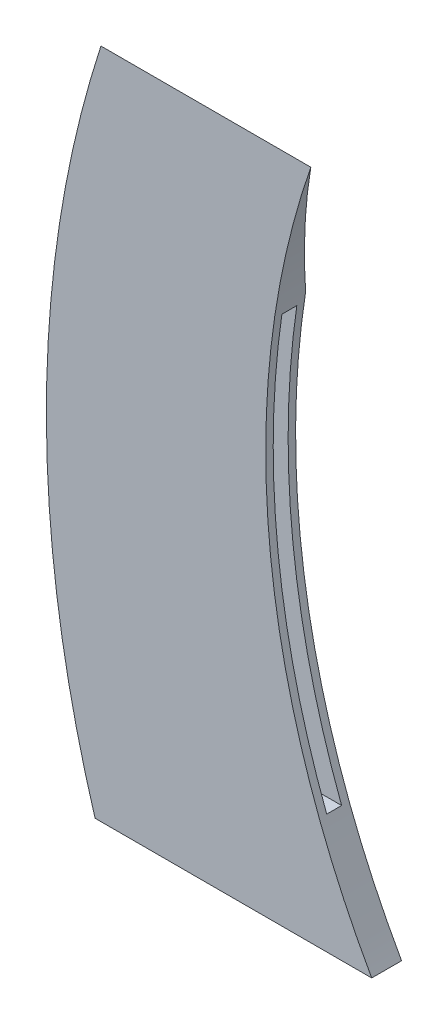
from build123d import *

# Parameters (mm, degrees)
EXTRUDE_1_DEPTH          = 4
CUT_EXTRUDE_1_DEPTH      = 38.06287663
CUT_EXTRUDE_1_DEPTH_BACK = 7.523724759
SKETCH_3_W               = 30
SKETCH_3_H               = 55
CUT_EXTRUDE_2_DEPTH      = 1


with BuildPart() as part:
    # 草图1 → 凸台-拉伸1 (new body)
    with BuildSketch(Plane.XY):
        with BuildLine():
            Line((0, 0), (37.06287663, 0))
            ThreePointArc((37.06287663, 0), (23.31417126, 44.123406063), (28.903445872, 90))
            Line((28.903445872, 90), (0.782681423, 90))
            ThreePointArc((0.782681423, 90), (-6.518052949, 45.060087267), (0, 0))
        make_face()
    extrude(amount=EXTRUDE_1_DEPTH)

    # 草图2 → 切除-拉伸1 (cut, two sides)
    with BuildSketch(Plane(origin=(0, 0, 0), x_dir=(0, 0, -1), z_dir=(1, 0, 0))) as cut_extrude_1_sk:
        Polygon((-4, 90), (0, 90), (0, 71.181479562), align=None)
    extrude(amount=CUT_EXTRUDE_1_DEPTH, mode=Mode.SUBTRACT)
    extrude(cut_extrude_1_sk.sketch, amount=-CUT_EXTRUDE_1_DEPTH_BACK, mode=Mode.SUBTRACT)

    # 草图3 → 切除-拉伸2 (cut, symmetric)
    with BuildSketch(Plane(origin=(0, 0, 2), x_dir=(-1, 0, 0), z_dir=(0, 0, -1))):
        with Locations((-23, 42.5)):
            Rectangle(SKETCH_3_W, SKETCH_3_H)
    extrude(amount=CUT_EXTRUDE_2_DEPTH, both=True, mode=Mode.SUBTRACT)


solid = part.part
